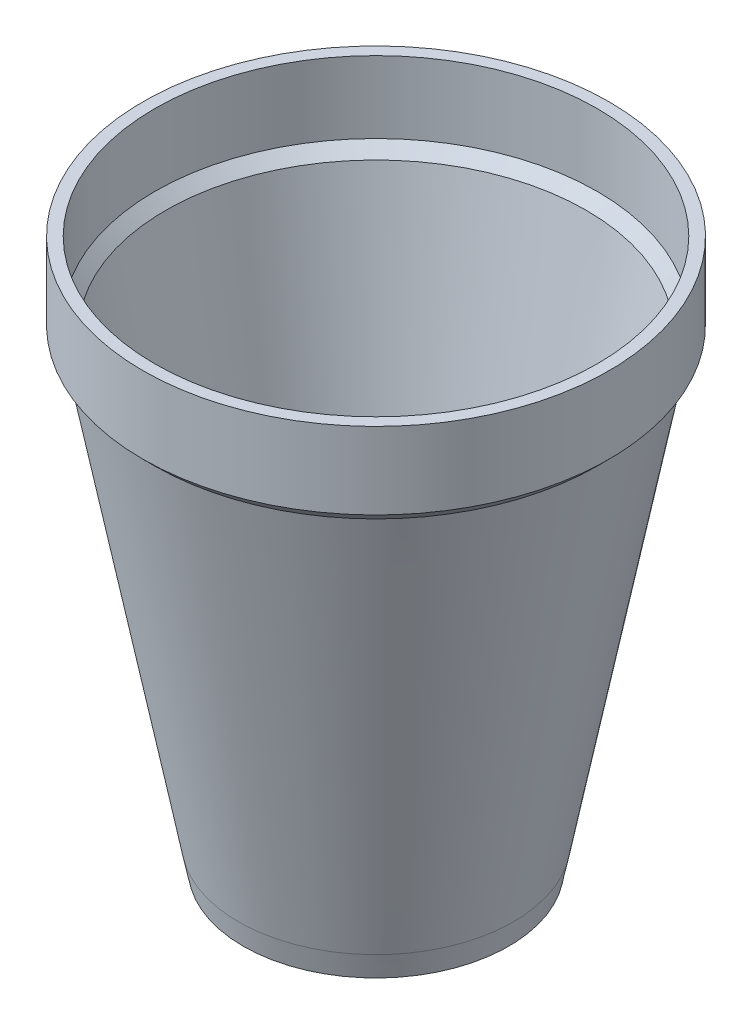
from build123d import *

# Parameters (mm, degrees)
VACIADO4_T              = -2
CROQUIS7_R              = 23.32
SALIENTE_EXTRUIR3_DEPTH = 4
SALIENTE_EXTRUIR3_TAPER = 11.46
CROQUIS8_R              = 20
CORTAR_EXTRUIR1_DEPTH   = 1
CORTAR_EXTRUIR1_DRAFT   = 11.46
CROQUIS10_W             = 0.897435898
CROQUIS10_H             = 5.128205128
CROQUIS10_W_2           = 0.897435897
CROQUIS10_H_2           = 5
CORTAR_EXTRUIR3_DEPTH   = 1.5
REDONDEO1_R             = 0.5


with BuildPart() as part:
    # Croquis1 → Revolución4 (revolve)
    with BuildSketch(Plane.XY, mode=Mode.PRIVATE) as revoluci_n4_sk:
        Polygon((0, 0), (23.32, 0), (37.5, 74), (39.5, 76), (39.5, 89), (0, 89), align=None)
    revolve(revoluci_n4_sk.sketch.rotate(Axis((0, 0, 0), (0, 1, 0)), 90), axis=Axis((0, 0, 0), (0, 1, 0)))

    # Vaciado4
    vaciado4_openings = [part.faces().sort_by_distance(p)[0] for p in [
        (0, 89, 0),
    ]]
    offset(amount=VACIADO4_T, openings=vaciado4_openings, kind=Kind.INTERSECTION)

    # Croquis7 → Saliente-Extruir3 (add)
    with BuildSketch(Plane(origin=(0, 0, 0), x_dir=(-1, 0, 0), z_dir=(0, -1, 0))):
        Circle(CROQUIS7_R)
    extrude(amount=SALIENTE_EXTRUIR3_DEPTH, taper=SALIENTE_EXTRUIR3_TAPER)


with BuildPart() as cortar_extruir1_tool:
    # Croquis8 → Cortar-Extruir1 (with draft: the straight prism first)
    with BuildSketch(Plane(origin=(0, -4, 0), x_dir=(-1, 0, 0), z_dir=(0, -1, 0))):
        Circle(CROQUIS8_R)
    extrude(amount=-CORTAR_EXTRUIR1_DEPTH)
    # Cortar-Extruir1: the draft: its side faces are tilted about the plane it starts from
    cortar_extruir1_sides = [cortar_extruir1_tool.faces().sort_by_distance(p)[0] for p in [
        (20, -3.5, 0),
    ]]
    draft(cortar_extruir1_sides, Plane(origin=(0, -4, 0), x_dir=(-1, 0, 0), z_dir=(0, -1, 0)), CORTAR_EXTRUIR1_DRAFT)


with BuildPart() as part_1:
    add(part.part)

    # Cortar-Extruir1: cut by cortar_extruir1_tool
    add(cortar_extruir1_tool.part, mode=Mode.SUBTRACT)

    # Croquis10 → Cortar-Extruir3 (cut)
    with BuildSketch(Plane(origin=(0, -3, 0), x_dir=(-1, 0, 0), z_dir=(0, -1, 0))):
        with BuildLine():
            Line((-16.121794872, -3.08994391), (-15.572916667, -2.5))
            add(Edge.make_bspline(
                [(-15.572916667, -2.5), (-15.545513343, -2.530335683), (-15.493101166, -2.588356352), (-15.412786599, -2.667340143), (-15.333729225, -2.733672819), (-15.256655771, -2.787942427), (-15.181951991, -2.831295124), (-15.10853631, -2.861468863), (-15.03672115, -2.880898741), (-14.989093356, -2.883399821), (-14.965945513, -2.884615385)],
                knots=[0, 0, 0, 0, 1.327744026, 2.539471363, 3.655870504, 4.675815953, 5.598594117, 6.454522034, 7.248873844, 8, 8, 8, 8], degree=3))
            add(Edge.make_bspline(
                [(-14.965945513, -2.884615385), (-14.942521526, -2.883906845), (-14.897671878, -2.882550213), (-14.834421155, -2.870759004), (-14.778975572, -2.850787781), (-14.732528496, -2.822585807), (-14.695067146, -2.788481153), (-14.667341594, -2.750115173), (-14.649765146, -2.707074449), (-14.648225161, -2.67678287), (-14.647435897, -2.661258013)],
                knots=[0, 0, 0, 0, 1.295920031, 2.481283723, 3.545621622, 4.54096118, 5.469720012, 6.331312947, 7.144774583, 8, 8, 8, 8], degree=3))
            add(Edge.make_bspline(
                [(-14.647435897, -2.661258013), (-14.649956136, -2.637643536), (-14.655204532, -2.588466398), (-14.693794056, -2.532889515), (-14.741812226, -2.489961906), (-14.79874137, -2.45160709), (-14.875430425, -2.40796014), (-14.933748898, -2.378205736), (-14.965945513, -2.361778846)],
                knots=[0, 0, 0, 0, 0.917114853, 1.909891267, 2.547779306, 3.439139809, 4.586193582, 6, 6, 6, 6], degree=3))
            Line((-14.965945513, -2.361778846), (-15.290464744, -2.197516026))
            add(Edge.make_bspline(
                [(-15.290464744, -2.197516026), (-15.331756509, -2.176562103), (-15.411870289, -2.135907557), (-15.524393346, -2.070150928), (-15.628882127, -2.00686886), (-15.721127564, -1.940205106), (-15.805363066, -1.875918341), (-15.877457025, -1.808988905), (-15.941066118, -1.743341699), (-16.011914311, -1.655199221), (-16.082809508, -1.537841483), (-16.141904684, -1.385206111), (-16.179591317, -1.221771694), (-16.183760733, -1.108651745), (-16.185897436, -1.05068109)],
                knots=[0, 0, 0, 0, 1.076723934, 2.08904669, 3.030727471, 3.916304557, 4.734969869, 5.493452046, 6.201990317, 6.859314016, 8.120513813, 9.372210561, 10.65333501, 12, 12, 12, 12], degree=3))
            add(Edge.make_bspline(
                [(-16.185897436, -1.05068109), (-16.18460896, -1.011572216), (-16.182087072, -0.935025771), (-16.16617253, -0.822347321), (-16.137503007, -0.715243008), (-16.100153433, -0.612150985), (-16.048861682, -0.515254021), (-15.987635379, -0.423130703), (-15.916104374, -0.334969411), (-15.832954642, -0.253692885), (-15.741351524, -0.178407714), (-15.640980716, -0.113080942), (-15.532711283, -0.059187188), (-15.417982694, -0.01354784), (-15.295128889, 0.021342502), (-15.16473635, 0.046036897), (-15.026743965, 0.061434932), (-14.932266392, 0.063198254), (-14.883814103, 0.064102564)],
                knots=[0, 0, 0, 0, 0.976822692, 1.911901239, 2.834103221, 3.741677305, 4.644181532, 5.564572461, 6.500876952, 7.4737059, 8.463396961, 9.457853255, 10.457191201, 11.479092582, 12.537356171, 13.641151563, 14.790277904, 16, 16, 16, 16], degree=3))
            add(Edge.make_bspline(
                [(-14.883814103, 0.064102564), (-14.819619287, 0.062053557), (-14.693610516, 0.058031537), (-14.509548241, 0.030145205), (-14.335581734, -0.018564777), (-14.171530147, -0.085529845), (-14.017447314, -0.172807307), (-13.8743263, -0.279574009), (-13.739964078, -0.404813687), (-13.661766647, -0.500809914), (-13.621794872, -0.549879808)],
                knots=[0, 0, 0, 0, 1.05686243, 2.074527901, 3.056146141, 4.024905077, 4.984922021, 5.963410766, 6.95896724, 8, 8, 8, 8], degree=3))
            Line((-13.621794872, -0.549879808), (-14.165665064, -1.153846154))
            add(Edge.make_bspline(
                [(-14.165665064, -1.153846154), (-14.192246585, -1.125999996), (-14.245168428, -1.070560354), (-14.332881856, -0.995686225), (-14.428546613, -0.931071483), (-14.527967243, -0.874569764), (-14.627851277, -0.829573394), (-14.722975874, -0.79381343), (-14.813593323, -0.77443675), (-14.872057006, -0.770907783), (-14.899839744, -0.769230769)],
                knots=[0, 0, 0, 0, 1.087723913, 2.165577914, 3.25186805, 4.346325896, 5.393672352, 6.34588318, 7.213941181, 8, 8, 8, 8], degree=3))
            add(Edge.make_bspline(
                [(-14.899839744, -0.769230769), (-14.927628067, -0.770043157), (-14.981044894, -0.771604791), (-15.057053262, -0.787600902), (-15.124364918, -0.815104336), (-15.182317689, -0.851535071), (-15.228413832, -0.895647463), (-15.262908444, -0.943563639), (-15.284204123, -0.995935633), (-15.287045257, -1.032469347), (-15.288461538, -1.05068109)],
                knots=[0, 0, 0, 0, 1.254483913, 2.411464304, 3.487299846, 4.525231271, 5.485593624, 6.352008169, 7.178490183, 8, 8, 8, 8], degree=3))
            add(Edge.make_bspline(
                [(-15.288461538, -1.05068109), (-15.287255475, -1.067860399), (-15.284779196, -1.103132832), (-15.265174408, -1.155197468), (-15.234394507, -1.206749811), (-15.191704463, -1.257935211), (-15.13653623, -1.30833836), (-15.069087244, -1.357555544), (-14.990913552, -1.408212562), (-14.933170014, -1.438448017), (-14.902844551, -1.454326923)],
                knots=[0, 0, 0, 0, 0.704666567, 1.446816302, 2.258757648, 3.165368109, 4.175243826, 5.322435858, 6.59381024, 8, 8, 8, 8], degree=3))
            Line((-14.902844551, -1.454326923), (-14.60536859, -1.604567308))
            add(Edge.make_bspline(
                [(-14.60536859, -1.604567308), (-14.537898307, -1.640760199), (-14.40838066, -1.71023698), (-14.233177412, -1.829247969), (-14.085226459, -1.956531744), (-13.962478945, -2.089251773), (-13.867150538, -2.230723487), (-13.799401992, -2.379151902), (-13.757040639, -2.535066843), (-13.75235856, -2.641631439), (-13.75, -2.6953125)],
                knots=[0, 0, 0, 0, 1.255902281, 2.4108615, 3.467482043, 4.45262019, 5.368926162, 6.254037486, 7.120485373, 8, 8, 8, 8], degree=3))
            add(Edge.make_bspline(
                [(-13.75, -2.6953125), (-13.750814477, -2.730107066), (-13.752413428, -2.798414452), (-13.769483587, -2.898715177), (-13.795170052, -2.995182005), (-13.831900941, -3.087995097), (-13.877482227, -3.177630422), (-13.935898513, -3.262047928), (-14.002994639, -3.343733101), (-14.080699607, -3.420066609), (-14.166351418, -3.48958788), (-14.25774329, -3.551490932), (-14.355751653, -3.602573045), (-14.459387327, -3.644738833), (-14.568630467, -3.677958189), (-14.683744026, -3.700634243), (-14.804323295, -3.715030908), (-14.886776927, -3.716962334), (-14.928886218, -3.717948718)],
                knots=[0, 0, 0, 0, 0.958838075, 1.882354927, 2.798264616, 3.708042778, 4.63064089, 5.565475101, 6.533511613, 7.542848948, 8.564005966, 9.572881083, 10.582092379, 11.606441752, 12.655212552, 13.726187313, 14.838757778, 16, 16, 16, 16], degree=3))
            add(Edge.make_bspline(
                [(-14.928886218, -3.717948718), (-14.987139237, -3.716206854), (-15.102491847, -3.712757616), (-15.272331634, -3.679478895), (-15.437620454, -3.630334131), (-15.595955187, -3.558259282), (-15.746026949, -3.468851994), (-15.884422807, -3.360003615), (-16.012164607, -3.234694568), (-16.084888566, -3.138673264), (-16.121794872, -3.08994391)],
                knots=[0, 0, 0, 0, 0.996693714, 1.973652574, 2.954136654, 3.944725065, 4.94508696, 5.939185155, 6.954167756, 8, 8, 8, 8], degree=3))
        make_face()
        with BuildLine():
            Line((-13.044871795, -3.08994391), (-12.49599359, -2.5))
            add(Edge.make_bspline(
                [(-12.49599359, -2.5), (-12.468590266, -2.530335683), (-12.416178089, -2.588356352), (-12.335863522, -2.667340143), (-12.256806148, -2.733672819), (-12.179732694, -2.787942427), (-12.105028914, -2.831295124), (-12.031613233, -2.861468863), (-11.959798073, -2.880898741), (-11.912170279, -2.883399821), (-11.889022436, -2.884615385)],
                knots=[0, 0, 0, 0, 1.327744026, 2.539471363, 3.655870504, 4.675815953, 5.598594117, 6.454522034, 7.248873844, 8, 8, 8, 8], degree=3))
            add(Edge.make_bspline(
                [(-11.889022436, -2.884615385), (-11.865598449, -2.883906845), (-11.820748801, -2.882550213), (-11.757498078, -2.870759004), (-11.702052495, -2.850787781), (-11.655605419, -2.822585807), (-11.618144069, -2.788481153), (-11.590418517, -2.750115173), (-11.572842069, -2.707074449), (-11.571302084, -2.67678287), (-11.570512821, -2.661258013)],
                knots=[0, 0, 0, 0, 1.295920031, 2.481283723, 3.545621622, 4.54096118, 5.469720012, 6.331312947, 7.144774583, 8, 8, 8, 8], degree=3))
            add(Edge.make_bspline(
                [(-11.570512821, -2.661258013), (-11.573033059, -2.637643536), (-11.578281455, -2.588466398), (-11.616870979, -2.532889515), (-11.664889149, -2.489961906), (-11.721818293, -2.45160709), (-11.798507348, -2.40796014), (-11.856825821, -2.378205736), (-11.889022436, -2.361778846)],
                knots=[0, 0, 0, 0, 0.917114853, 1.909891267, 2.547779306, 3.439139809, 4.586193582, 6, 6, 6, 6], degree=3))
            Line((-11.889022436, -2.361778846), (-12.213541667, -2.197516026))
            add(Edge.make_bspline(
                [(-12.213541667, -2.197516026), (-12.254833432, -2.176562103), (-12.334947212, -2.135907557), (-12.447470269, -2.070150928), (-12.55195905, -2.00686886), (-12.644204487, -1.940205106), (-12.728439989, -1.875918341), (-12.800533948, -1.808988905), (-12.864143041, -1.743341699), (-12.934991235, -1.655199221), (-13.005886431, -1.537841483), (-13.064981607, -1.385206111), (-13.10266824, -1.221771694), (-13.106837656, -1.108651745), (-13.108974359, -1.05068109)],
                knots=[0, 0, 0, 0, 1.076723934, 2.08904669, 3.030727471, 3.916304557, 4.734969869, 5.493452046, 6.201990317, 6.859314016, 8.120513813, 9.372210561, 10.65333501, 12, 12, 12, 12], degree=3))
            add(Edge.make_bspline(
                [(-13.108974359, -1.05068109), (-13.107685883, -1.011572216), (-13.105163995, -0.935025771), (-13.089249453, -0.822347321), (-13.06057993, -0.715243008), (-13.023230356, -0.612150985), (-12.971938605, -0.515254021), (-12.910712302, -0.423130703), (-12.839181297, -0.334969411), (-12.756031565, -0.253692885), (-12.664428447, -0.178407714), (-12.564057639, -0.113080942), (-12.455788206, -0.059187188), (-12.341059617, -0.01354784), (-12.218205812, 0.021342502), (-12.087813273, 0.046036897), (-11.949820888, 0.061434932), (-11.855343315, 0.063198254), (-11.806891026, 0.064102564)],
                knots=[0, 0, 0, 0, 0.976822692, 1.911901239, 2.834103221, 3.741677305, 4.644181532, 5.564572461, 6.500876952, 7.4737059, 8.463396961, 9.457853255, 10.457191201, 11.479092582, 12.537356171, 13.641151563, 14.790277904, 16, 16, 16, 16], degree=3))
            add(Edge.make_bspline(
                [(-11.806891026, 0.064102564), (-11.74269621, 0.062053557), (-11.616687439, 0.058031537), (-11.432625164, 0.030145205), (-11.258658657, -0.018564777), (-11.094607071, -0.085529845), (-10.940524237, -0.172807307), (-10.797403223, -0.279574009), (-10.663041001, -0.404813687), (-10.58484357, -0.500809914), (-10.544871795, -0.549879808)],
                knots=[0, 0, 0, 0, 1.05686243, 2.074527901, 3.056146141, 4.024905077, 4.984922021, 5.963410766, 6.95896724, 8, 8, 8, 8], degree=3))
            Line((-10.544871795, -0.549879808), (-11.088741987, -1.153846154))
            add(Edge.make_bspline(
                [(-11.088741987, -1.153846154), (-11.115323508, -1.125999996), (-11.168245351, -1.070560354), (-11.255958779, -0.995686225), (-11.351623536, -0.931071483), (-11.451044166, -0.874569764), (-11.5509282, -0.829573394), (-11.646052797, -0.79381343), (-11.736670246, -0.77443675), (-11.795133929, -0.770907783), (-11.822916667, -0.769230769)],
                knots=[0, 0, 0, 0, 1.087723913, 2.165577914, 3.25186805, 4.346325896, 5.393672352, 6.34588318, 7.213941181, 8, 8, 8, 8], degree=3))
            add(Edge.make_bspline(
                [(-11.822916667, -0.769230769), (-11.85070499, -0.770043157), (-11.904121818, -0.771604791), (-11.980130185, -0.787600902), (-12.047441841, -0.815104336), (-12.105394612, -0.851535071), (-12.151490755, -0.895647463), (-12.185985367, -0.943563639), (-12.207281046, -0.995935633), (-12.21012218, -1.032469347), (-12.211538462, -1.05068109)],
                knots=[0, 0, 0, 0, 1.254483913, 2.411464304, 3.487299846, 4.525231271, 5.485593624, 6.352008169, 7.178490183, 8, 8, 8, 8], degree=3))
            add(Edge.make_bspline(
                [(-12.211538462, -1.05068109), (-12.210332399, -1.067860399), (-12.207856119, -1.103132832), (-12.188251332, -1.155197468), (-12.15747143, -1.206749811), (-12.114781386, -1.257935211), (-12.059613153, -1.30833836), (-11.992164167, -1.357555544), (-11.913990475, -1.408212562), (-11.856246937, -1.438448017), (-11.825921474, -1.454326923)],
                knots=[0, 0, 0, 0, 0.704666567, 1.446816302, 2.258757648, 3.165368109, 4.175243826, 5.322435858, 6.59381024, 8, 8, 8, 8], degree=3))
            Line((-11.825921474, -1.454326923), (-11.528445513, -1.604567308))
            add(Edge.make_bspline(
                [(-11.528445513, -1.604567308), (-11.46097523, -1.640760199), (-11.331457583, -1.71023698), (-11.156254335, -1.829247969), (-11.008303382, -1.956531744), (-10.885555868, -2.089251773), (-10.790227461, -2.230723487), (-10.722478915, -2.379151902), (-10.680117562, -2.535066843), (-10.675435483, -2.641631439), (-10.673076923, -2.6953125)],
                knots=[0, 0, 0, 0, 1.255902281, 2.4108615, 3.467482043, 4.45262019, 5.368926162, 6.254037486, 7.120485373, 8, 8, 8, 8], degree=3))
            add(Edge.make_bspline(
                [(-10.673076923, -2.6953125), (-10.6738914, -2.730107066), (-10.675490351, -2.798414452), (-10.69256051, -2.898715177), (-10.718246975, -2.995182005), (-10.754977864, -3.087995097), (-10.80055915, -3.177630422), (-10.858975436, -3.262047928), (-10.926071562, -3.343733101), (-11.00377653, -3.420066609), (-11.089428341, -3.48958788), (-11.180820213, -3.551490932), (-11.278828576, -3.602573045), (-11.38246425, -3.644738833), (-11.49170739, -3.677958189), (-11.606820949, -3.700634243), (-11.727400218, -3.715030908), (-11.80985385, -3.716962334), (-11.851963141, -3.717948718)],
                knots=[0, 0, 0, 0, 0.958838075, 1.882354927, 2.798264616, 3.708042778, 4.63064089, 5.565475101, 6.533511613, 7.542848948, 8.564005966, 9.572881083, 10.582092379, 11.606441752, 12.655212552, 13.726187313, 14.838757778, 16, 16, 16, 16], degree=3))
            add(Edge.make_bspline(
                [(-11.851963141, -3.717948718), (-11.91021616, -3.716206854), (-12.02556877, -3.712757616), (-12.195408557, -3.679478895), (-12.360697377, -3.630334131), (-12.51903211, -3.558259282), (-12.669103872, -3.468851994), (-12.80749973, -3.360003615), (-12.93524153, -3.234694568), (-13.007965489, -3.138673264), (-13.044871795, -3.08994391)],
                knots=[0, 0, 0, 0, 0.996693714, 1.973652574, 2.954136654, 3.944725065, 4.94508696, 5.939185155, 6.954167756, 8, 8, 8, 8], degree=3))
        make_face()
        with BuildLine():
            Line((-9.006410256, -3.653846154), (-9.903846154, -3.653846154))
            Line((-9.903846154, -3.653846154), (-9.903846154, 0))
            Line((-9.903846154, 0), (-9.006410256, 0))
            Line((-9.006410256, 0), (-9.006410256, -0.398637821))
            add(Edge.make_bspline(
                [(-9.006410256, -0.398637821), (-8.961864283, -0.359950209), (-8.87526174, -0.284737002), (-8.740310523, -0.185446806), (-8.603120266, -0.106763499), (-8.46641301, -0.041454765), (-8.325471837, 0.005133987), (-8.180477714, 0.039758786), (-8.029412865, 0.059935177), (-7.926741399, 0.062698965), (-7.874599359, 0.064102564)],
                knots=[0, 0, 0, 0, 1.129087683, 2.195077524, 3.200104641, 4.152071996, 5.089690739, 6.035159067, 7.002149119, 8, 8, 8, 8], degree=3))
            add(Edge.make_bspline(
                [(-7.874599359, 0.064102564), (-7.816065355, 0.062786189), (-7.700398845, 0.060184958), (-7.530676209, 0.032786923), (-7.366772185, -0.009117803), (-7.208914874, -0.068542495), (-7.056873022, -0.145168343), (-6.911430651, -0.238776029), (-6.771930547, -0.349170693), (-6.640523928, -0.475233339), (-6.518926153, -0.613173348), (-6.412047314, -0.760790905), (-6.322229331, -0.917305306), (-6.249249186, -1.081929858), (-6.191603384, -1.254596533), (-6.150546829, -1.435699372), (-6.126314564, -1.625272641), (-6.123316029, -1.754403688), (-6.121794872, -1.819911859)],
                knots=[0, 0, 0, 0, 0.980635182, 1.937790695, 2.874612845, 3.813473129, 4.759763495, 5.72404569, 6.708444218, 7.737858197, 8.773145527, 9.787642451, 10.788159158, 11.793035368, 12.802034882, 13.835443946, 14.901920881, 16, 16, 16, 16], degree=3))
            add(Edge.make_bspline(
                [(-6.121794872, -1.819911859), (-6.123389721, -1.887746413), (-6.126518197, -2.020811449), (-6.149454547, -2.216063436), (-6.189670598, -2.401695385), (-6.245059146, -2.578000802), (-6.314663648, -2.745500739), (-6.402994773, -2.902189259), (-6.505473554, -3.050468342), (-6.622844756, -3.187516355), (-6.75163028, -3.310847332), (-6.887477149, -3.420332948), (-7.030604879, -3.512804444), (-7.181372528, -3.587403931), (-7.338192975, -3.645619644), (-7.501834498, -3.688120133), (-7.672467048, -3.71366283), (-7.788708381, -3.716508224), (-7.84755609, -3.717948718)],
                knots=[0, 0, 0, 0, 1.136340375, 2.229058262, 3.287747549, 4.313796199, 5.321476843, 6.32056726, 7.321347234, 8.336944959, 9.337787455, 10.30479778, 11.255888616, 12.186428358, 13.117354666, 14.053442213, 15.014546185, 16, 16, 16, 16], degree=3))
            add(Edge.make_bspline(
                [(-7.84755609, -3.717948718), (-7.90207417, -3.71684478), (-8.009945799, -3.714660484), (-8.168312405, -3.68992784), (-8.322342252, -3.654691732), (-8.470612075, -3.602171786), (-8.613838998, -3.534598421), (-8.75100062, -3.451928132), (-8.8839341, -3.355601796), (-8.965080465, -3.280459351), (-9.006410256, -3.2421875)],
                knots=[0, 0, 0, 0, 1.016860689, 2.012000776, 2.985574089, 3.963288254, 4.94189597, 5.937036056, 6.949282938, 8, 8, 8, 8], degree=3))
            Line((-9.006410256, -3.2421875), (-9.006410256, -3.653846154))
        make_face()
        with BuildLine():
            add(Edge.make_bspline(
                [(-8.035857372, -2.884615385), (-8.000097483, -2.883517661), (-7.930010437, -2.881366194), (-7.826932962, -2.868437371), (-7.728440566, -2.845619492), (-7.635147993, -2.812037659), (-7.54614317, -2.77076201), (-7.461407285, -2.720748464), (-7.382156743, -2.659788895), (-7.307600588, -2.591235534), (-7.239171193, -2.515789608), (-7.181632454, -2.432808304), (-7.13054503, -2.346280493), (-7.089336185, -2.253942257), (-7.058829531, -2.155904554), (-7.035024839, -2.05325615), (-7.022612722, -1.945080385), (-7.020369367, -1.871353693), (-7.019230769, -1.833934295)],
                knots=[0, 0, 0, 0, 1.048146026, 2.054297773, 3.039291333, 4.004895774, 4.954855183, 5.911393651, 6.882091317, 7.879305688, 8.877191939, 9.859995919, 10.833402353, 11.818978979, 12.815424932, 13.838562528, 14.902979527, 16, 16, 16, 16], degree=3))
            add(Edge.make_bspline(
                [(-7.019230769, -1.833934295), (-7.020352457, -1.796175633), (-7.022562729, -1.721772626), (-7.035219508, -1.612682206), (-7.058190742, -1.508542273), (-7.091949955, -1.41036475), (-7.132278947, -1.316316945), (-7.18462106, -1.228749804), (-7.244283184, -1.145381805), (-7.313524541, -1.068543678), (-7.389080645, -0.99937551), (-7.468772698, -0.936912036), (-7.553686374, -0.885302299), (-7.642924857, -0.842624097), (-7.735887233, -0.809558843), (-7.83362407, -0.786447872), (-7.935281417, -0.772283459), (-8.004762272, -0.770255359), (-8.039863782, -0.769230769)],
                knots=[0, 0, 0, 0, 1.099575806, 2.166701374, 3.192649988, 4.197894673, 5.185929295, 6.166282287, 7.161891816, 8.166995477, 9.171440763, 10.141716722, 11.110384286, 12.058293159, 13.017598555, 13.97724868, 14.978112372, 16, 16, 16, 16], degree=3))
            add(Edge.make_bspline(
                [(-8.039863782, -0.769230769), (-8.076290298, -0.770333704), (-8.14770607, -0.772496055), (-8.252457332, -0.785320118), (-8.352301525, -0.80817305), (-8.446742825, -0.84212391), (-8.537675649, -0.882598288), (-8.623005808, -0.934272239), (-8.703534434, -0.995011971), (-8.779242552, -1.06320532), (-8.847237716, -1.139777209), (-8.907952101, -1.221686538), (-8.958097873, -1.310733799), (-8.999167419, -1.405111862), (-9.031371276, -1.505077218), (-9.054595528, -1.610668324), (-9.067200789, -1.722117532), (-9.069394852, -1.79818133), (-9.070512821, -1.836939103)],
                knots=[0, 0, 0, 0, 1.050055163, 2.05867895, 3.036770115, 3.995495956, 4.947241397, 5.901173699, 6.863515112, 7.851357518, 8.832757047, 9.810564118, 10.784575339, 11.771479801, 12.772731182, 13.807147486, 14.882647436, 16, 16, 16, 16], degree=3))
            add(Edge.make_bspline(
                [(-9.070512821, -1.836939103), (-9.069409776, -1.875030698), (-9.067255211, -1.949434651), (-9.054529558, -2.058550688), (-9.031193458, -2.162090655), (-8.999371887, -2.26052148), (-8.958098015, -2.353194527), (-8.907640008, -2.440355517), (-8.847259965, -2.521135381), (-8.779165119, -2.596621201), (-8.703810244, -2.663920959), (-8.622534961, -2.7229124), (-8.536539461, -2.772683103), (-8.445947073, -2.81459252), (-8.349823823, -2.845007278), (-8.249832597, -2.868618236), (-8.144354559, -2.881358905), (-8.072613285, -2.883512177), (-8.035857372, -2.884615385)],
                knots=[0, 0, 0, 0, 1.106253802, 2.160835036, 3.183977744, 4.183421548, 5.159890935, 6.124302589, 7.101541683, 8.083003376, 9.071668641, 10.029626693, 10.994038348, 11.952829982, 12.921617172, 13.916395167, 14.932486243, 16, 16, 16, 16], degree=3))
        make_face(mode=Mode.SUBTRACT)
        with Locations((-4.967948718, -2.564102564)):
            Rectangle(CROQUIS10_W, CROQUIS10_H)
        with BuildLine():
            Line((-3.460536859, -4.204727564), (-2.781450321, -3.5546875))
            add(Edge.make_bspline(
                [(-2.781450321, -3.5546875), (-2.727685854, -3.608516386), (-2.622191095, -3.714137546), (-2.449667614, -3.851610745), (-2.270985647, -3.968490141), (-2.085557079, -4.064596556), (-1.893123609, -4.139145047), (-1.694064989, -4.192471968), (-1.488057377, -4.224101068), (-1.348599419, -4.228529035), (-1.278044872, -4.230769231)],
                knots=[0, 0, 0, 0, 1.075575784, 2.110457258, 3.113929901, 4.09197124, 5.059417775, 6.02750972, 7.002078037, 8, 8, 8, 8], degree=3))
            add(Edge.make_bspline(
                [(-1.278044872, -4.230769231), (-1.216876302, -4.229199448), (-1.096766452, -4.226117041), (-0.920275479, -4.202712015), (-0.751631828, -4.163608311), (-0.590018649, -4.109459646), (-0.436496495, -4.038911801), (-0.290132876, -3.953559455), (-0.15259856, -3.851268076), (-0.023312426, -3.736158424), (0.094168667, -3.609541199), (0.1980836, -3.475150425), (0.285789884, -3.333182731), (0.357086049, -3.184376904), (0.412618493, -3.029308022), (0.451467647, -2.867438116), (0.476362865, -2.699089458), (0.479287746, -2.584222867), (0.480769231, -2.526041667)],
                knots=[0, 0, 0, 0, 1.07509559, 2.111044432, 3.123295838, 4.114414616, 5.101929537, 6.088414859, 7.087392227, 8.109987248, 9.127465927, 10.119435877, 11.091852952, 12.055283684, 13.015060431, 13.981632522, 14.977674508, 16, 16, 16, 16], degree=3))
            add(Edge.make_bspline(
                [(0.480769231, -2.526041667), (0.479373951, -2.465852024), (0.47662506, -2.347270187), (0.45054271, -2.173181483), (0.409656133, -2.006056414), (0.352420198, -1.845700094), (0.277805962, -1.692568723), (0.185939765, -1.546919675), (0.078177681, -1.408111509), (-0.04453677, -1.27804244), (-0.178099718, -1.158236621), (-0.322632884, -1.054646968), (-0.474093727, -0.966226036), (-0.633440129, -0.892916478), (-0.801213966, -0.838833651), (-0.975971933, -0.798056417), (-1.15850133, -0.773720437), (-1.282980338, -0.770742223), (-1.346153846, -0.769230769)],
                knots=[0, 0, 0, 0, 1.021985222, 2.013450793, 2.98331293, 3.941376853, 4.900279932, 5.871285843, 6.861761207, 7.88100394, 8.905520213, 9.905129641, 10.896449179, 11.881305449, 12.878594847, 13.885755381, 14.927013861, 16, 16, 16, 16], degree=3))
            add(Edge.make_bspline(
                [(-1.346153846, -0.769230769), (-1.387249008, -0.769601928), (-1.467927955, -0.770330595), (-1.586272761, -0.782142218), (-1.699609047, -0.799054112), (-1.808420068, -0.821353283), (-1.91174786, -0.853331532), (-2.010994726, -0.889518625), (-2.104857047, -0.934352871), (-2.194152841, -0.985231851), (-2.278963068, -1.043830294), (-2.35901375, -1.109884663), (-2.434574352, -1.183996308), (-2.506946786, -1.264744533), (-2.573673888, -1.354487807), (-2.637115948, -1.451001491), (-2.696440269, -1.555354873), (-2.731497155, -1.629039458), (-2.749399038, -1.666666667)],
                knots=[0, 0, 0, 0, 1.109467577, 2.178131716, 3.208562196, 4.204278576, 5.174223432, 6.127254264, 7.054993225, 7.9799672, 8.900446918, 9.835649638, 10.779420865, 11.756673556, 12.761211291, 13.796640546, 14.874849225, 16, 16, 16, 16], degree=3))
            Line((-2.749399038, -1.666666667), (-1.314102564, -1.666666667))
            Line((-1.314102564, -1.666666667), (-1.314102564, -2.564102564))
            Line((-1.314102564, -2.564102564), (-3.807091346, -2.564102564))
            Line((-3.807091346, -2.564102564), (-3.814102564, -2.350761218))
            add(Edge.make_bspline(
                [(-3.814102564, -2.350761218), (-3.813201675, -2.295969747), (-3.811401504, -2.186484586), (-3.79494983, -2.023479832), (-3.76769788, -1.862637), (-3.730441865, -1.704117626), (-3.683750622, -1.547144154), (-3.624204788, -1.393219596), (-3.554476551, -1.241300615), (-3.476352626, -1.092030744), (-3.388557781, -0.94880811), (-3.294055447, -0.813173929), (-3.194094228, -0.685462441), (-3.08701664, -0.567262955), (-2.973055958, -0.458705799), (-2.853588409, -0.358423052), (-2.728572449, -0.265539326), (-2.595793696, -0.183657281), (-2.457483767, -0.110653582), (-2.313650287, -0.045749278), (-2.163451292, 0.007865786), (-2.007560118, 0.052178874), (-1.845903268, 0.086265679), (-1.678546631, 0.109665485), (-1.505379135, 0.125558661), (-1.387924013, 0.127312308), (-1.328125, 0.128205128)],
                knots=[0, 0, 0, 0, 1.006947556, 2.012098127, 3.007912615, 4.003802745, 5.003693661, 6.015789779, 7.034654729, 8.075083123, 9.110776623, 10.12033905, 11.112364132, 12.089932562, 13.049221985, 14.003156825, 14.955669239, 15.909347409, 16.867458246, 17.828943829, 18.807340259, 19.796171017, 20.806031855, 21.841452577, 22.901035528, 24, 24, 24, 24], degree=3))
            add(Edge.make_bspline(
                [(-1.328125, 0.128205128), (-1.264327335, 0.127304547), (-1.137861336, 0.125519328), (-0.951125674, 0.109458556), (-0.769816463, 0.081474938), (-0.593304062, 0.046848836), (-0.422502648, -0.002569689), (-0.25629651, -0.059490753), (-0.096303531, -0.129924687), (0.058793209, -0.208183759), (0.206997714, -0.297845494), (0.348402795, -0.395495441), (0.481074877, -0.503265306), (0.605570656, -0.620049509), (0.722774442, -0.744833835), (0.831539662, -0.879296095), (0.932843334, -1.022138407), (1.024209002, -1.174308792), (1.107175269, -1.331657749), (1.179484347, -1.493240772), (1.240491565, -1.657572861), (1.291276703, -1.82503542), (1.32981875, -1.995818715), (1.358364557, -2.169678406), (1.374239518, -2.346458262), (1.37687739, -2.465248531), (1.378205128, -2.525040064)],
                knots=[0, 0, 0, 0, 1.084248544, 2.149304005, 3.182186427, 4.201621716, 5.204046643, 6.201899409, 7.185482703, 8.172726097, 9.152750634, 10.127173101, 11.09142983, 12.055001688, 13.026594436, 13.998833283, 14.992319766, 16.000574469, 17.013370274, 18.014203756, 19.007155264, 19.990967713, 20.986267719, 21.980774716, 22.98364929, 24, 24, 24, 24], degree=3))
            add(Edge.make_bspline(
                [(1.378205128, -2.525040064), (1.376437091, -2.606611536), (1.372945741, -2.767691008), (1.340487116, -3.004939101), (1.290243322, -3.234232017), (1.217060998, -3.454935179), (1.12480286, -3.667938342), (1.012221264, -3.873054083), (0.878383034, -4.070019018), (0.774735025, -4.19195116), (0.722155449, -4.25380609)],
                knots=[0, 0, 0, 0, 1.034063014, 2.041967874, 3.031271063, 4.007437694, 4.986016733, 5.971461028, 6.970942901, 8, 8, 8, 8], degree=3))
            add(Edge.make_bspline(
                [(0.722155449, -4.25380609), (0.689511578, -4.289591919), (0.624713985, -4.360626253), (0.521135151, -4.459329904), (0.414929528, -4.552114988), (0.304626153, -4.637014055), (0.190804869, -4.715885587), (0.073138078, -4.787251073), (-0.047756966, -4.853382829), (-0.172823099, -4.910903916), (-0.301405581, -4.962476369), (-0.434073885, -5.006113915), (-0.569834353, -5.044766409), (-0.709889147, -5.074171044), (-0.85282338, -5.098656979), (-0.999651647, -5.115068736), (-1.149973833, -5.127097385), (-1.251644199, -5.12783296), (-1.303084936, -5.128205128)],
                knots=[0, 0, 0, 0, 1.020590567, 2.025856924, 3.013483481, 3.991664875, 4.957826714, 5.930500614, 6.890802512, 7.860442893, 8.829981142, 9.809047939, 10.802672283, 11.803273349, 12.823572789, 13.857849586, 14.916166035, 16, 16, 16, 16], degree=3))
            add(Edge.make_bspline(
                [(-1.303084936, -5.128205128), (-1.356857207, -5.127375867), (-1.463844282, -5.125725943), (-1.622916345, -5.11430954), (-1.779777995, -5.096696723), (-1.933768202, -5.07027649), (-2.085403757, -5.037694844), (-2.233899759, -4.995949692), (-2.38022496, -4.94851968), (-2.475482112, -4.91070497), (-2.523036859, -4.891826923)],
                knots=[0, 0, 0, 0, 1.03180557, 2.052914215, 3.058998889, 4.059601663, 5.049854447, 6.033765722, 7.018406786, 8, 8, 8, 8], degree=3))
            add(Edge.make_bspline(
                [(-2.523036859, -4.891826923), (-2.563052455, -4.874386053), (-2.64444307, -4.838911806), (-2.762778478, -4.773896091), (-2.881891429, -4.70218646), (-2.998552905, -4.619092048), (-3.116140957, -4.529328697), (-3.232256259, -4.429781033), (-3.347770073, -4.321365206), (-3.422461127, -4.244110291), (-3.460536859, -4.204727564)],
                knots=[0, 0, 0, 0, 0.894422958, 1.819231551, 2.765348375, 3.743239639, 4.753552307, 5.797344382, 6.877138289, 8, 8, 8, 8], degree=3))
        make_face()
        with BuildLine():
            add(Edge.make_bspline(
                [(4.60536859, -5.128205128), (4.518437028, -5.12595523), (4.346814436, -5.121513421), (4.094427048, -5.08445956), (3.851175964, -5.024155094), (3.617026315, -4.93997977), (3.392776668, -4.830965177), (3.17760307, -4.698600261), (2.972095184, -4.541761852), (2.778649025, -4.36268804), (2.601263632, -4.16687643), (2.445339857, -3.958113045), (2.312980337, -3.738553278), (2.205543794, -3.508154351), (2.121643602, -3.267232742), (2.063333956, -3.015697018), (2.025737278, -2.753869285), (2.021423274, -2.575585212), (2.019230769, -2.484975962)],
                knots=[0, 0, 0, 0, 1.014151002, 2.002163778, 2.969868608, 3.93493411, 4.9003771, 5.874719092, 6.87846472, 7.912488755, 8.947011879, 9.957751389, 10.948740761, 11.933621513, 12.919426746, 13.920294397, 14.943031967, 16, 16, 16, 16], degree=3))
            add(Edge.make_bspline(
                [(2.019230769, -2.484975962), (2.021566429, -2.39538784), (2.026168923, -2.218851573), (2.061794548, -1.959434229), (2.121117634, -1.710602006), (2.20340033, -1.472269835), (2.308958323, -1.24443381), (2.439296458, -1.027833231), (2.593558409, -0.822023051), (2.768593042, -0.628264143), (2.960102163, -0.451244702), (3.164151669, -0.295843377), (3.378845835, -0.165136518), (3.602812946, -0.05664702), (3.838165878, 0.02487975), (4.082295291, 0.08590278), (4.337243397, 0.121189656), (4.510444038, 0.125843119), (4.598357372, 0.128205128)],
                knots=[0, 0, 0, 0, 1.051517626, 2.07204922, 3.067438659, 4.05042616, 5.027204762, 6.009981242, 7.012629434, 8.042243656, 9.071350414, 10.070091277, 11.048190212, 12.017682766, 12.985867053, 13.966945899, 14.968060614, 16, 16, 16, 16], degree=3))
            add(Edge.make_bspline(
                [(4.598357372, 0.128205128), (4.690311294, 0.126111129), (4.870988182, 0.121996707), (5.135475253, 0.083200495), (5.38851557, 0.024050502), (5.629415795, -0.061584455), (5.857988655, -0.17285516), (6.075259204, -0.307206044), (6.279593374, -0.46723228), (6.470310059, -0.648107204), (6.643079709, -0.84607537), (6.795588075, -1.055197861), (6.924230945, -1.273893209), (7.029014925, -1.502259589), (7.11162232, -1.738878852), (7.169892472, -1.985191786), (7.204314036, -2.240607723), (7.209108761, -2.41409133), (7.211538462, -2.502003205)],
                knots=[0, 0, 0, 0, 1.067953136, 2.098381936, 3.099641766, 4.083805132, 5.062469929, 6.048665414, 7.046702845, 8.073106546, 9.098695993, 10.09591865, 11.076726721, 12.041940862, 13.011263376, 13.984305721, 14.978557872, 16, 16, 16, 16], degree=3))
            add(Edge.make_bspline(
                [(7.211538462, -2.502003205), (7.210765361, -2.561143149), (7.209228948, -2.678674188), (7.191127605, -2.852894399), (7.164281101, -3.023464353), (7.127528881, -3.190704802), (7.07801142, -3.354184754), (7.017826968, -3.514316581), (6.947693112, -3.671099397), (6.86681658, -3.823115323), (6.775329087, -3.968545569), (6.677645129, -4.108660334), (6.570023204, -4.239781327), (6.454684675, -4.363332844), (6.331177773, -4.478750104), (6.199287394, -4.586427206), (6.059221134, -4.686089514), (5.912493995, -4.778560582), (5.759607896, -4.859550871), (5.604200286, -4.932962638), (5.444779269, -4.992484879), (5.282502351, -5.041783072), (5.117742619, -5.081346876), (4.949227986, -5.107653431), (4.778380676, -5.125897776), (4.663176149, -5.127434186), (4.60536859, -5.128205128)],
                knots=[0, 0, 0, 0, 1.034641744, 2.056182551, 3.061960284, 4.05571729, 5.050247014, 6.048716841, 7.047801973, 8.054190544, 9.059424999, 10.053182006, 11.041513076, 12.025412457, 13.009311837, 13.997642908, 15.002928308, 16.016213968, 17.030509951, 18.02913364, 19.022134519, 20.005478534, 20.996155877, 21.984625117, 22.988721131, 24, 24, 24, 24], degree=3))
        make_face()
        with BuildLine():
            add(Edge.make_bspline(
                [(4.619391026, -4.230769231), (4.67789566, -4.229199418), (4.793360398, -4.226101236), (4.962726188, -4.202497336), (5.125323142, -4.164799077), (5.280250793, -4.110194133), (5.428177384, -4.040694027), (5.569377218, -3.956550009), (5.701849186, -3.854837557), (5.827536277, -3.741138915), (5.940690986, -3.61392917), (6.042432397, -3.479087555), (6.124694458, -3.333369553), (6.195428086, -3.181574722), (6.24767581, -3.019864331), (6.287457004, -2.850862927), (6.309124471, -2.67283559), (6.312419559, -2.551802866), (6.314102564, -2.489983974)],
                knots=[0, 0, 0, 0, 1.033668485, 2.040047952, 3.016132939, 3.979056467, 4.937231767, 5.900589077, 6.877725736, 7.88429546, 8.891280164, 9.882584218, 10.863295226, 11.842887319, 12.837417301, 13.860812229, 14.907384602, 16, 16, 16, 16], degree=3))
            add(Edge.make_bspline(
                [(6.314102564, -2.489983974), (6.312056789, -2.421455658), (6.308047409, -2.287151513), (6.280247328, -2.091127219), (6.231536169, -1.906214718), (6.164990856, -1.731795415), (6.076533152, -1.569703428), (5.970735742, -1.417973666), (5.844949689, -1.277547532), (5.748215427, -1.195492596), (5.69911859, -1.153846154)],
                knots=[0, 0, 0, 0, 1.078343132, 2.113373867, 3.107373148, 4.082093053, 5.043582658, 6.005574554, 6.987742499, 8, 8, 8, 8], degree=3))
            add(Edge.make_bspline(
                [(5.69911859, -1.153846154), (5.658888192, -1.12308424), (5.579333794, -1.062253484), (5.452347654, -0.984286392), (5.321576935, -0.917460816), (5.186034807, -0.863466541), (5.046007529, -0.820995551), (4.901514303, -0.791253816), (4.752759862, -0.772588305), (4.652165138, -0.770357423), (4.601362179, -0.769230769)],
                knots=[0, 0, 0, 0, 1.023928204, 2.024787132, 3.009472467, 3.9914905, 4.972207045, 5.96565515, 6.972602802, 8, 8, 8, 8], degree=3))
            add(Edge.make_bspline(
                [(4.601362179, -0.769230769), (4.543864646, -0.770816138), (4.430736441, -0.773935402), (4.264507595, -0.79721665), (4.10532918, -0.836789352), (3.951725781, -0.890527648), (3.805754263, -0.962546271), (3.665138309, -1.048062864), (3.53155382, -1.149744504), (3.406629275, -1.266308446), (3.292142608, -1.393524191), (3.190853769, -1.529095151), (3.106969912, -1.6730266), (3.037000099, -1.823395927), (2.982485822, -1.981400386), (2.945178707, -2.147051895), (2.921202138, -2.319682124), (2.918197396, -2.43715174), (2.916666667, -2.496995192)],
                knots=[0, 0, 0, 0, 1.026350473, 2.019376834, 2.989435443, 3.95094063, 4.91865229, 5.889827372, 6.885283771, 7.910196595, 8.935871797, 9.9372888, 10.925850568, 11.904605667, 12.894245083, 13.903507864, 14.931967858, 16, 16, 16, 16], degree=3))
            add(Edge.make_bspline(
                [(2.916666667, -2.496995192), (2.918244429, -2.556496983), (2.921350014, -2.673617183), (2.94476173, -2.845768516), (2.983682911, -3.010509824), (3.038690979, -3.168265768), (3.107219586, -3.319864557), (3.193302925, -3.463990442), (3.295075096, -3.60051873), (3.410675619, -3.728637741), (3.536478986, -3.846378798), (3.671546926, -3.948554622), (3.812093626, -4.037342686), (3.961345603, -4.106895545), (4.116248849, -4.162308194), (4.277748707, -4.203114855), (4.446456838, -4.225935423), (4.561232468, -4.229143599), (4.619391026, -4.230769231)],
                knots=[0, 0, 0, 0, 1.055040155, 2.076685641, 3.074845078, 4.052329834, 5.035358467, 6.020382375, 7.023447318, 8.050688466, 9.077178457, 10.074336316, 11.0503314, 12.019748348, 12.988025369, 13.964577102, 14.968620271, 16, 16, 16, 16], degree=3))
        make_face(mode=Mode.SUBTRACT)
        with BuildLine():
            Line((7.852564103, -4.132612179), (8.510616987, -3.503605769))
            add(Edge.make_bspline(
                [(8.510616987, -3.503605769), (8.566373419, -3.561409327), (8.67546049, -3.674501583), (8.852076653, -3.822551661), (9.033645318, -3.948375646), (9.22067469, -4.050931138), (9.413057329, -4.132320001), (9.611127947, -4.189096836), (9.814408098, -4.224846894), (9.951775723, -4.228784148), (10.021033654, -4.230769231)],
                knots=[0, 0, 0, 0, 1.115370381, 2.182214363, 3.196266025, 4.180416361, 5.141116029, 6.092551847, 7.038303877, 8, 8, 8, 8], degree=3))
            add(Edge.make_bspline(
                [(10.021033654, -4.230769231), (10.078864756, -4.229170198), (10.192988064, -4.226014683), (10.360535153, -4.202825898), (10.520863369, -4.163541101), (10.674099912, -4.108935518), (10.8210024, -4.040168778), (10.96020291, -3.953733945), (11.092449521, -3.852515885), (11.21619704, -3.736691717), (11.327914282, -3.609208912), (11.428573104, -3.474946666), (11.511948107, -3.331530205), (11.580007028, -3.18105098), (11.633639022, -3.023454653), (11.671703801, -2.858749111), (11.693758559, -2.68656248), (11.697046779, -2.569507043), (11.698717949, -2.510016026)],
                knots=[0, 0, 0, 0, 1.035268443, 2.04298821, 3.02163646, 3.985902049, 4.951223231, 5.920091634, 6.913651787, 7.92868536, 8.949353712, 9.945284791, 10.92850487, 11.913014323, 12.897904816, 13.904240668, 14.934873455, 16, 16, 16, 16], degree=3))
            add(Edge.make_bspline(
                [(11.698717949, -2.510016026), (11.698229461, -2.468262293), (11.697266643, -2.385964827), (11.686992799, -2.264536818), (11.669930429, -2.146468177), (11.645999107, -2.032108726), (11.615871608, -1.920965145), (11.578998418, -1.81376137), (11.534415189, -1.710359856), (11.48451915, -1.610218957), (11.428824512, -1.514187213), (11.366393377, -1.423538102), (11.297925333, -1.338976008), (11.226160029, -1.257558462), (11.146344609, -1.184050143), (11.06205269, -1.114399902), (10.972074844, -1.050333224), (10.876520342, -0.992741686), (10.778241375, -0.939067372), (10.675224056, -0.894618126), (10.570347093, -0.854660901), (10.46177059, -0.824601045), (10.351407118, -0.798455325), (10.237720519, -0.78248732), (10.121789722, -0.770353748), (10.043436513, -0.769606707), (10.00400641, -0.769230769)],
                knots=[0, 0, 0, 0, 1.103833241, 2.175677997, 3.219414644, 4.256521947, 5.263082927, 6.262573145, 7.25136242, 8.238376666, 9.219530388, 10.184343756, 11.145312504, 12.095474572, 13.051075647, 14.010745898, 14.985684176, 15.968306307, 16.959653902, 17.943861036, 18.93268972, 19.924626761, 20.920484516, 21.929288403, 22.957944781, 24, 24, 24, 24], degree=3))
            add(Edge.make_bspline(
                [(10.00400641, -0.769230769), (9.937125013, -0.771160914), (9.805720459, -0.774953146), (9.612893799, -0.80473733), (9.428620209, -0.853510136), (9.281675251, -0.912174259), (9.166697804, -0.969204166), (9.079212124, -1.02120008), (8.989127237, -1.080096797), (8.897059925, -1.147525849), (8.802511819, -1.222684798), (8.707107177, -1.307144561), (8.608416732, -1.398145661), (8.543765084, -1.46309401), (8.510616987, -1.496394231)],
                knots=[0, 0, 0, 0, 1.404640003, 2.759752344, 4.088613405, 5.401587939, 6.076032573, 6.783413463, 7.538272532, 8.336594406, 9.180107851, 10.074881764, 11.012956238, 12, 12, 12, 12], degree=3))
            Line((8.510616987, -1.496394231), (7.872596154, -0.826322115))
            add(Edge.make_bspline(
                [(7.872596154, -0.826322115), (7.917445584, -0.783021397), (8.004982079, -0.698507654), (8.137028462, -0.578506054), (8.268908625, -0.47067117), (8.397436773, -0.371089562), (8.524717785, -0.282660588), (8.650740057, -0.205301846), (8.77407037, -0.137036113), (8.897292894, -0.079086559), (9.021385781, -0.029567331), (9.149010509, 0.012194738), (9.280228057, 0.048650162), (9.416125175, 0.077338701), (9.556095503, 0.100693158), (9.700588815, 0.116125268), (9.848929992, 0.126826466), (9.949232354, 0.127741824), (10, 0.128205128)],
                knots=[0, 0, 0, 0, 1.244537013, 2.429070097, 3.56066612, 4.644477994, 5.67429546, 6.652817684, 7.595405349, 8.486886006, 9.369351459, 10.26090686, 11.166404474, 12.086719576, 13.0323422, 13.998023148, 14.9867073, 16, 16, 16, 16], degree=3))
            add(Edge.make_bspline(
                [(10, 0.128205128), (10.093250282, 0.125823791), (10.275715164, 0.121164177), (10.543138471, 0.086758442), (10.797394197, 0.028697012), (11.038939202, -0.052302313), (11.267034256, -0.157479505), (11.48239467, -0.285099944), (11.684661802, -0.436374883), (11.872095163, -0.609050467), (12.041584435, -0.799796274), (12.191562676, -1.004526459), (12.315079031, -1.224711244), (12.41987631, -1.455634126), (12.498405951, -1.700905324), (12.555568609, -1.958308528), (12.590351788, -2.228948344), (12.594194194, -2.413758462), (12.596153846, -2.508012821)],
                knots=[0, 0, 0, 0, 1.07798487, 2.109316747, 3.111276023, 4.08905949, 5.049398091, 6.009992678, 6.978127636, 7.964347882, 8.951383687, 9.924270623, 10.892397886, 11.86520058, 12.851549246, 13.863953586, 14.910602472, 16, 16, 16, 16], degree=3))
            add(Edge.make_bspline(
                [(12.596153846, -2.508012821), (12.595297975, -2.569482094), (12.593601848, -2.69129917), (12.576880859, -2.871210941), (12.551230132, -3.045864831), (12.514723124, -3.215046029), (12.469331505, -3.379340317), (12.411554539, -3.538003822), (12.344633976, -3.691905124), (12.266504941, -3.839609992), (12.178926463, -3.981305079), (12.083179503, -4.116632227), (11.977420286, -4.244245399), (11.86265382, -4.364702738), (11.739833924, -4.478782796), (11.607759427, -4.585675938), (11.466304041, -4.684692836), (11.316910658, -4.775914868), (11.162423401, -4.85968971), (11.002732478, -4.929934708), (10.840949954, -4.991944007), (10.675979664, -5.042030271), (10.507458506, -5.079810465), (10.336673343, -5.108320613), (10.162228746, -5.124277114), (10.045102239, -5.126887449), (9.985977564, -5.128205128)],
                knots=[0, 0, 0, 0, 1.07193642, 2.124315995, 3.14887099, 4.149444713, 5.141371803, 6.119544533, 7.092241254, 8.06650569, 9.031360777, 9.996057679, 10.955696533, 11.919602115, 12.89624813, 13.877605408, 14.880920851, 15.905674436, 16.929600311, 17.943674756, 18.946313929, 19.950355855, 20.947755382, 21.956851243, 22.968632213, 24, 24, 24, 24], degree=3))
            add(Edge.make_bspline(
                [(9.985977564, -5.128205128), (9.935538536, -5.127448852), (9.835184906, -5.125944164), (9.68573739, -5.113423119), (9.537501447, -5.093703113), (9.390929741, -5.064157735), (9.245363147, -5.028376922), (9.101411113, -4.984304619), (8.959470593, -4.93054674), (8.818311074, -4.87107918), (8.680747772, -4.803378451), (8.547976207, -4.727600751), (8.419667392, -4.645728496), (8.296594817, -4.556353472), (8.177891631, -4.46078848), (8.063684485, -4.359036686), (7.955069285, -4.249252335), (7.886905232, -4.171688786), (7.852564103, -4.132612179)],
                knots=[0, 0, 0, 0, 0.996333415, 1.982307736, 2.96084097, 3.949129141, 4.93457382, 5.921430247, 6.92116383, 7.931890485, 8.946633814, 9.948019707, 10.950686436, 11.952094051, 12.951305284, 13.960287133, 14.972390273, 16, 16, 16, 16], degree=3))
        make_face()
        Polygon((15.929487179, -5), (13.237179487, -5), (13.237179487, -4.102564103), (15.032051282, -4.102564103), (15.032051282, -3.141025641), (13.237179487, -3.141025641), (13.237179487, -2.243589744), (15.032051282, -2.243589744), (15.032051282, -0.897435897), (13.237179487, -0.897435897), (13.237179487, 0), (15.929487179, 0), align=None)
        with Locations((-4.711538461, 6.897435897)):
            Rectangle(CROQUIS10_W_2, CROQUIS10_H_2)
        Polygon((0.737179487, 4.397435897), (-0.071113782, 4.397435897), (-2.33974359, 7.687700321), (-2.33974359, 4.397435897), (-3.237179487, 4.397435897), (-3.237179487, 9.397435897), (-2.422876603, 9.397435897), (-0.16025641, 6.1171875), (-0.16025641, 9.397435897), (0.737179487, 9.397435897), align=None)
        with BuildLine():
            Line((5.16025641, 4.397435897), (4.262820513, 4.397435897))
            Line((4.262820513, 4.397435897), (4.262820513, 7.650641026))
            add(Edge.make_bspline(
                [(4.262820513, 7.650641026), (4.26276973, 7.684368613), (4.262671644, 7.749513099), (4.257979682, 7.842977848), (4.253557567, 7.929210111), (4.246033479, 8.007510905), (4.234231416, 8.078123292), (4.223212529, 8.141307427), (4.208105431, 8.196500227), (4.185482483, 8.259367074), (4.150162949, 8.329991237), (4.094143047, 8.404432003), (4.027245797, 8.470690569), (3.94846406, 8.526324352), (3.860506988, 8.573380046), (3.761641195, 8.604503447), (3.655080664, 8.625613891), (3.580839862, 8.627325228), (3.542668269, 8.628205128)],
                knots=[0, 0, 0, 0, 1.155195489, 2.231248153, 3.20507519, 4.113220553, 4.92363642, 5.657123012, 6.309133385, 6.880755525, 7.944644177, 8.999147208, 10.058600405, 11.156792429, 12.29246015, 13.460660758, 14.694375292, 16, 16, 16, 16], degree=3))
            add(Edge.make_bspline(
                [(3.542668269, 8.628205128), (3.502154857, 8.627035803), (3.423160561, 8.624755817), (3.309308992, 8.601892827), (3.203531275, 8.566335634), (3.108717453, 8.514551067), (3.024525465, 8.453421169), (2.954675822, 8.382044539), (2.897149863, 8.304068939), (2.860987999, 8.230653575), (2.840013512, 8.16372343), (2.826273566, 8.103407998), (2.81456024, 8.033159035), (2.804264719, 7.952674274), (2.798271897, 7.861678233), (2.79152877, 7.760571482), (2.789098964, 7.649316327), (2.78868001, 7.571847778), (2.788461538, 7.531450321)],
                knots=[0, 0, 0, 0, 1.260834212, 2.45841325, 3.603280198, 4.724942815, 5.811019112, 6.833506895, 7.823953325, 8.819576102, 9.365694356, 10.006623749, 10.745436914, 11.584131356, 12.533575865, 13.586103333, 14.74122738, 16, 16, 16, 16], degree=3))
            Line((2.788461538, 7.531450321), (2.788461538, 4.397435897))
            Line((2.788461538, 4.397435897), (1.891025641, 4.397435897))
            Line((1.891025641, 4.397435897), (1.891025641, 7.380208333))
            add(Edge.make_bspline(
                [(1.891025641, 7.380208333), (1.891134136, 7.440640277), (1.891342762, 7.556845011), (1.895235515, 7.723821588), (1.902366591, 7.876410621), (1.911218514, 8.014335533), (1.921833747, 8.137990332), (1.935571705, 8.247311938), (1.952377119, 8.342241728), (1.977563748, 8.450295143), (2.02097073, 8.574717925), (2.090970023, 8.717986192), (2.179829784, 8.858245667), (2.284834742, 8.993998871), (2.403486629, 9.119971532), (2.532600299, 9.230932401), (2.671475877, 9.322885588), (2.819155686, 9.398046426), (2.978382003, 9.455392259), (3.149082572, 9.495739189), (3.331871484, 9.521735293), (3.457773363, 9.524313018), (3.522636218, 9.525641026)],
                knots=[0, 0, 0, 0, 1.170912322, 2.251550202, 3.235884933, 4.130507595, 4.929373885, 5.640290569, 6.26461063, 6.796528574, 7.788739464, 8.810047518, 9.879767716, 11.000329969, 12.130634485, 13.227340211, 14.291294104, 15.350161901, 16.430664233, 17.561930962, 18.743941553, 20, 20, 20, 20], degree=3))
            add(Edge.make_bspline(
                [(3.522636218, 9.525641026), (3.565736283, 9.524912888), (3.650771827, 9.523476288), (3.775842983, 9.510877849), (3.896704918, 9.492154079), (4.01343349, 9.465388303), (4.125583394, 9.42877706), (4.233758045, 9.385884252), (4.338071354, 9.335880206), (4.436174119, 9.276284717), (4.530112353, 9.212837651), (4.617476565, 9.144584561), (4.69787779, 9.072371999), (4.771248282, 8.996087382), (4.83758433, 8.91575636), (4.896904142, 8.831389626), (4.949078669, 8.742944084), (4.995432352, 8.648839106), (5.035102194, 8.54428733), (5.068562204, 8.425573895), (5.097649706, 8.291147095), (5.119669066, 8.140121397), (5.139076388, 7.973184431), (5.151651537, 7.78969913), (5.158142492, 7.590259199), (5.159533966, 7.451994489), (5.16025641, 7.380208333)],
                knots=[0, 0, 0, 0, 1.001274302, 1.975493657, 2.918061388, 3.842055805, 4.754744607, 5.656586832, 6.54484551, 7.438946169, 8.321187755, 9.177850665, 10.012845812, 10.830395126, 11.634995211, 12.431362049, 13.224358528, 14.018909421, 14.866105371, 15.818803578, 16.882454076, 18.059767828, 19.363726729, 20.787034531, 22.331848803, 24, 24, 24, 24], degree=3))
            Line((5.16025641, 7.380208333), (5.16025641, 4.397435897))
        make_face()
    extrude(amount=-CORTAR_EXTRUIR3_DEPTH, mode=Mode.SUBTRACT)

    # Redondeo1
    redondeo1_edges = [part_1.edges().sort_by_distance(p)[0] for p in [
        (20.202725373, -3, 0),
    ]]
    fillet(redondeo1_edges, radius=REDONDEO1_R)


solid = part_1.part
